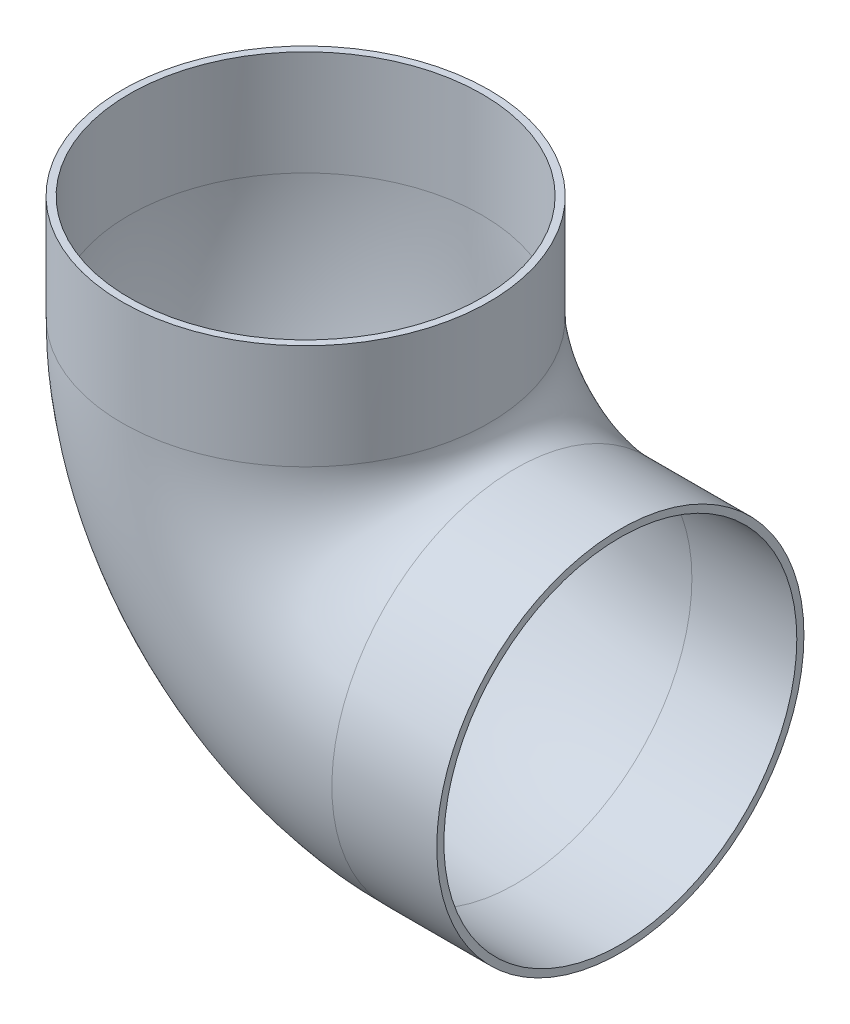
from build123d import *

# Parameters (mm, degrees)
SKETCH2_R   = 11.1125
SKETCH2_R_2 = 10.6807


with BuildPart() as part:
    # Sweep1: sweep along a path in Sketch1
    with BuildLine(Plane.XY) as sweep1_path:
        Line((-18.281933638, 1.917757526), (-18.281933638, -4.432242474))
        ThreePointArc((-18.281933638, -4.432242474), (-14.562189759, -13.412498595), (-5.581933638, -17.132242474))
        Line((-5.581933638, -17.132242474), (0.768066362, -17.132242474))
    # Sketch2 → Sweep1 (sweep)
    with BuildSketch(Plane(origin=(0.768066362, -17.132242474, 0), x_dir=(0, 0, -1), z_dir=(1, 0, 0))):
        Circle(SKETCH2_R)
        Circle(SKETCH2_R_2, mode=Mode.SUBTRACT)
    sweep(path=sweep1_path.line)


solid = part.part
